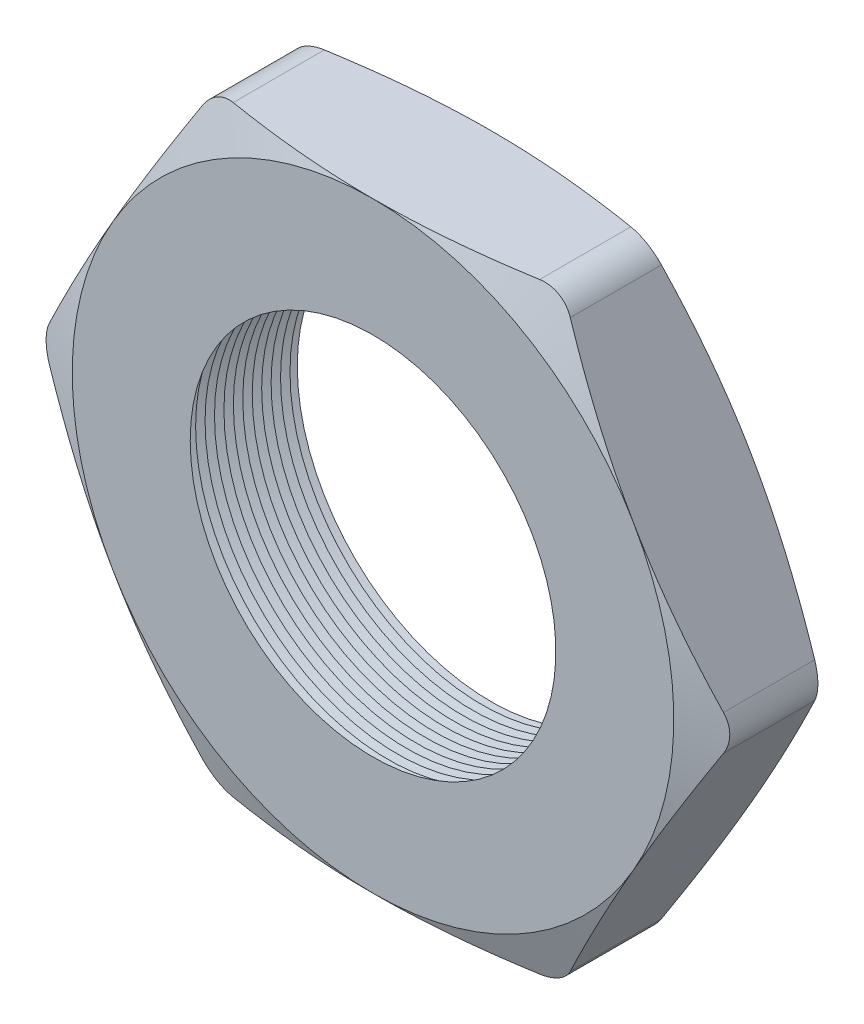
from build123d import *

# Parameters (mm, degrees)
SKETCH1_R          = 3.937
EXTRUDE1_DEPTH     = 2.54
FILLET1_R          = 0.762
SKETCH2_OUTSIDE_W  = 40.128
SKETCH2_OUTSIDE_H  = 38.36
SKETCH2_OUTSIDE_R  = 6.477
CUT_EXTRUDE1_DEPTH = 3.54
CUT_EXTRUDE1_DRAFT = -70
SKETCH3_OUTSIDE_W  = 40.128
SKETCH3_OUTSIDE_H  = 38.36
SKETCH3_OUTSIDE_R  = 6.477
CUT_EXTRUDE2_DEPTH = 3.5400001
CUT_EXTRUDE2_DRAFT = -70
LPATTERN1_COUNT    = 13
LPATTERN1_PITCH    = 0.2032


with BuildPart() as part:
    # Sketch1 → Extrude1 (new body)
    with BuildSketch(Plane.XY):
        Polygon((-7.478995387, 0), (-3.739497694, -6.477), (3.739497694, -6.477), (7.478995387, 0), (3.739497694, 6.477), (-3.739497694, 6.477), align=None)
        Circle(SKETCH1_R, mode=Mode.SUBTRACT)
    extrude(amount=EXTRUDE1_DEPTH)

    # Fillet1
    fillet1_edges = [part.edges().sort_by_distance(p)[0] for p in [
        (7.478995387, 0, 1.27),
        (3.739497694, -6.477, 1.27),
        (-3.739497694, -6.477, 1.27),
        (-7.478995387, 0, 1.27),
        (-3.739497694, 6.477, 1.27),
        (3.739497694, 6.477, 1.27),
    ]]
    fillet(fillet1_edges, radius=FILLET1_R)


with BuildPart() as cut_extrude1_tool:
    # Sketch2 outside → Cut-Extrude1 (with draft: the straight prism first)
    with BuildSketch(Plane.XY.offset(2.54)):
        Rectangle(SKETCH2_OUTSIDE_W, SKETCH2_OUTSIDE_H)
        Circle(SKETCH2_OUTSIDE_R, mode=Mode.SUBTRACT)
    extrude(amount=-CUT_EXTRUDE1_DEPTH)
    # Cut-Extrude1: the draft: its side faces are tilted about the plane it starts from
    cut_extrude1_sides = [cut_extrude1_tool.faces().sort_by_distance(p)[0] for p in [
        (0, -19.18, 0.77),
        (20.064, 0, 0.77),
        (0, 19.18, 0.77),
        (-20.064, 0, 0.77),
        (-6.477, 0, 0.77),
    ]]
    draft(cut_extrude1_sides, Plane.XY.offset(2.54), CUT_EXTRUDE1_DRAFT)


with BuildPart() as part_1:
    add(part.part)

    # Cut-Extrude1: cut by cut_extrude1_tool
    add(cut_extrude1_tool.part, mode=Mode.SUBTRACT)


with BuildPart() as cut_extrude2_tool:
    # Sketch3 outside → Cut-Extrude2 (with draft: the straight prism first)
    with BuildSketch(Plane(origin=(0, 0, 0), x_dir=(-1, 0, 0), z_dir=(0, 0, -1))):
        Rectangle(SKETCH3_OUTSIDE_W, SKETCH3_OUTSIDE_H)
        Circle(SKETCH3_OUTSIDE_R, mode=Mode.SUBTRACT)
    extrude(amount=-CUT_EXTRUDE2_DEPTH)
    # Cut-Extrude2: the draft: its side faces are tilted about the plane it starts from
    cut_extrude2_sides = [cut_extrude2_tool.faces().sort_by_distance(p)[0] for p in [
        (0, -19.18, 1.77000005),
        (-20.064, 0, 1.77000005),
        (0, 19.18, 1.77000005),
        (20.064, 0, 1.77000005),
        (6.477, 0, 1.77000005),
    ]]
    draft(cut_extrude2_sides, Plane(origin=(0, 0, 0), x_dir=(-1, 0, 0), z_dir=(0, 0, -1)), CUT_EXTRUDE2_DRAFT)


with BuildPart() as part_2:
    add(part_1.part)

    # Cut-Extrude2: cut by cut_extrude2_tool
    add(cut_extrude2_tool.part, mode=Mode.SUBTRACT)

    # Sketch4 → Cut-Revolve1 (revolve, cut)
    with BuildSketch(Plane(origin=(0, 0, 0), x_dir=(1, 0, 0), z_dir=(0, 1, 0))):
        Polygon((-3.937, -2.54), (-3.937, -2.100059095), (-4.318, -2.320029547), align=None)
    cut_revolve1 = revolve(axis=Axis((0, 0, 2.54), (0, 0, -1)), mode=Mode.SUBTRACT)

    # LPattern1: Cut-Revolve1 ×13
    with Locations(*[(0, 0, -i * LPATTERN1_PITCH) for i in range(1, LPATTERN1_COUNT)]):
        add(cut_revolve1, mode=Mode.SUBTRACT)


solid = part_2.part
